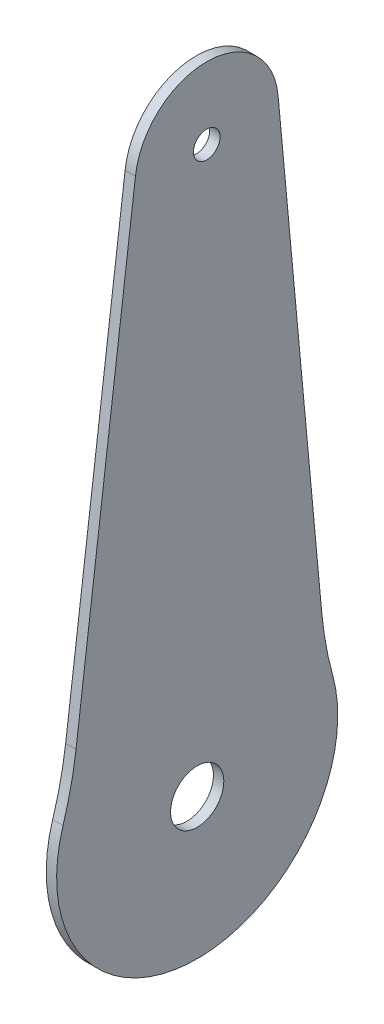
from build123d import *

# Parameters (mm, degrees)
SKETCH_2_R      = 3.85
SKETCH_2_R_2    = 1.925
EXTRUDE_1_DEPTH = 1.5


with BuildPart() as part:
    # 草圖2 → 填料-伸長1 (new body)
    with BuildSketch(Plane(origin=(0, 0, 0), x_dir=(0, 0, -1), z_dir=(1, 0, 0))):
        with BuildLine():
            Line((18.012072511, -21.441606673), (11.718522882, 46.276737912))
            ThreePointArc((11.718522882, 46.276737912), (1.55399875, 55.843411078), (-8.930005845, 46.627965677))
            Line((-8.930005845, 46.627965677), (-17.523002046, -20.837161438))
            ThreePointArc((-17.523002046, -20.837161438), (-18.27264724, -25.183298229), (-19.402359762, -29.446468708))
            ThreePointArc((-19.402359762, -29.446468708), (-19.752456192, -30.70663404), (-20.020797275, -31.986703271))
            ThreePointArc((-20.020797275, -31.986703271), (-0.345749536, -55.841970902), (20.12922907, -32.669648007))
            ThreePointArc((20.12922907, -32.669648007), (19.904578122, -31.38119307), (19.597542195, -30.109850035))
            ThreePointArc((19.597542195, -30.109850035), (18.61347279, -25.810724505), (18.012072511, -21.441606673))
        make_face()
        with Locations((0, -35.515504866)):
            Circle(SKETCH_2_R, mode=Mode.SUBTRACT)
        with Locations((1.377596172, 45.472779649)):
            Circle(SKETCH_2_R_2, mode=Mode.SUBTRACT)
    extrude(amount=EXTRUDE_1_DEPTH)


solid = part.part
